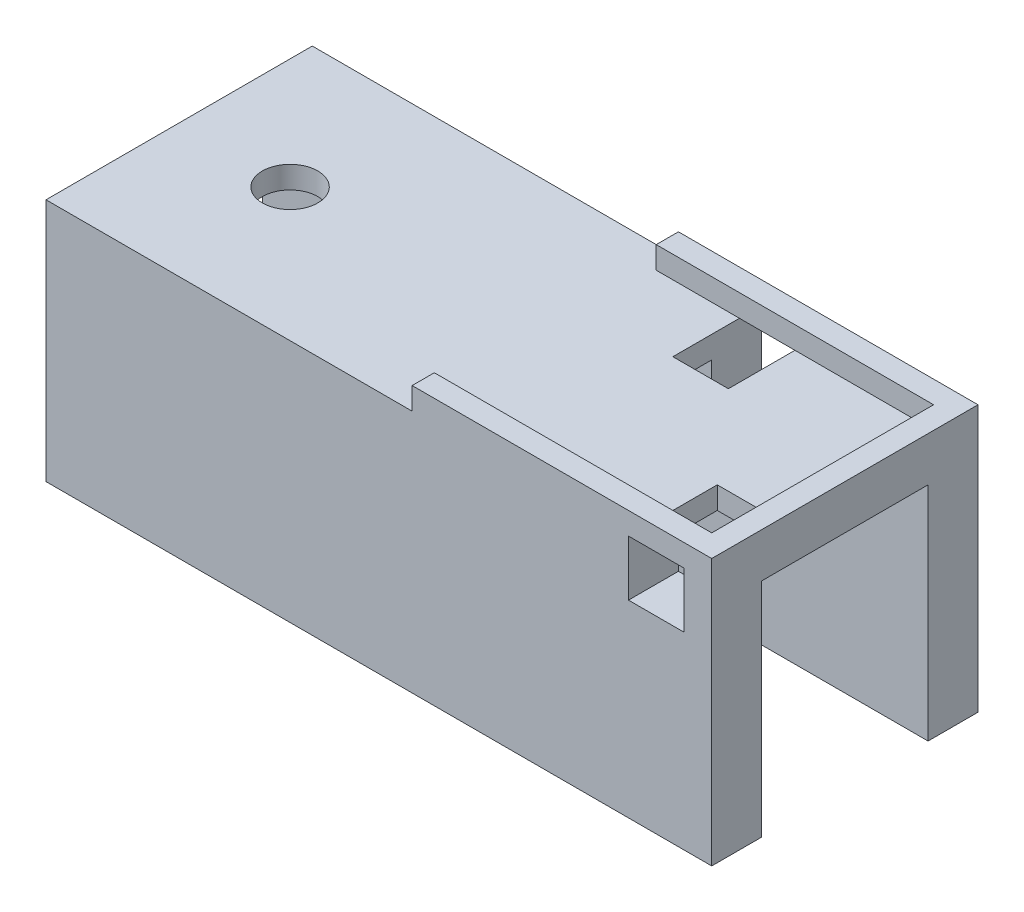
from build123d import *

# Parameters (mm, degrees)
ESQUISSE1_W             = 60
ESQUISSE1_H             = 24
ESQUISSE1_R             = 2.5
BOSS_EXTRU_1_DEPTH      = 2
BOSS_EXTRU_2_DEPTH      = 2
ESQUISSE3_W             = 60
ESQUISSE3_H             = 4.5
BOSS_EXTRU_3_DEPTH      = 20
ESQUISSE5_W             = 5
ESQUISSE5_H             = 5
ENL_V_MAT_EXTRU_2_DEPTH = 8
ESQUISSE6_W             = 5
ESQUISSE6_H             = 5
ENL_V_MAT_EXTRU_3_DEPTH = 8


with BuildPart() as part:
    # Esquisse1 → Boss.-Extru.1 (new body)
    with BuildSketch(Plane(origin=(0, 0, 0), x_dir=(1, 0, 0), z_dir=(0, 1, 0))):
        with Locations((30, 0)):
            Rectangle(ESQUISSE1_W, ESQUISSE1_H)
        with Locations((10, 0)):
            Circle(ESQUISSE1_R, mode=Mode.SUBTRACT)
    extrude(amount=BOSS_EXTRU_1_DEPTH)

    # Esquisse2 → Boss.-Extru.2 (add)
    with BuildSketch(Plane(origin=(0, 2, 0), x_dir=(1, 0, 0), z_dir=(0, 1, 0))):
        Polygon((60, 12), (33, 12), (33, 10), (58, 10), (58, -10), (33, -10), (33, -12), (60, -12), align=None)
    extrude(amount=BOSS_EXTRU_2_DEPTH)

    # Esquisse3 → Boss.-Extru.3 (add)
    with BuildSketch(Plane.XZ):
        with Locations((30, 9.75)):
            Rectangle(ESQUISSE3_W, ESQUISSE3_H)
        with Locations((30, -9.75)):
            Rectangle(ESQUISSE3_W, ESQUISSE3_H)
    extrude(amount=BOSS_EXTRU_3_DEPTH)

    # Esquisse5 → Enlèv. mat.-Extru.2 (cut)
    with BuildSketch(Plane.XY.offset(12)):
        with Locations((55, -0.5)):
            Rectangle(ESQUISSE5_W, ESQUISSE5_H)
    extrude(amount=-ENL_V_MAT_EXTRU_2_DEPTH, mode=Mode.SUBTRACT)

    # Esquisse6 → Enlèv. mat.-Extru.3 (cut)
    with BuildSketch(Plane(origin=(0, 0, -12), x_dir=(-1, 0, 0), z_dir=(0, 0, -1))):
        with Locations((-43, -0.5)):
            Rectangle(ESQUISSE6_W, ESQUISSE6_H)
    extrude(amount=-ENL_V_MAT_EXTRU_3_DEPTH, mode=Mode.SUBTRACT)


solid = part.part
